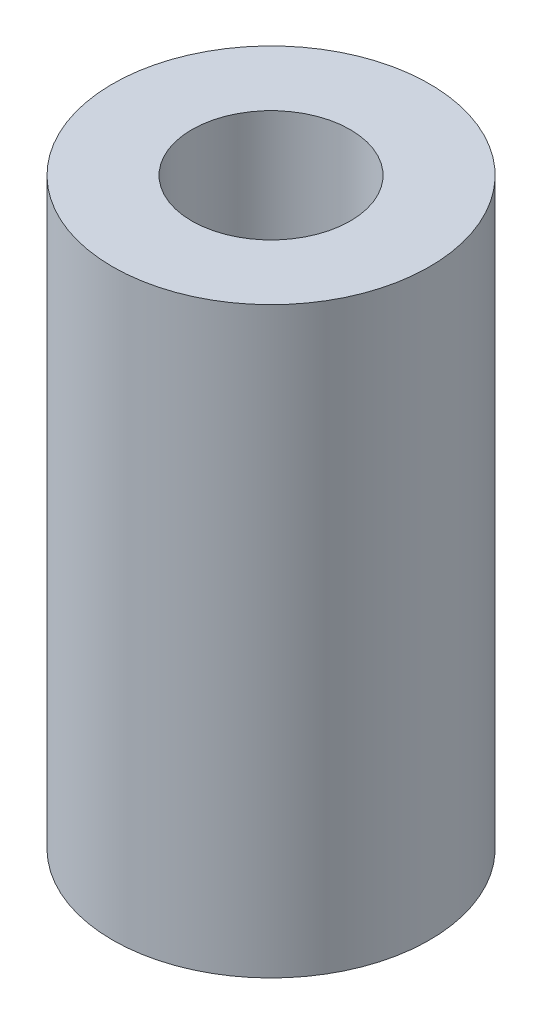
from build123d import *

# Parameters (mm, degrees)
SKETCH1_R           = 6.35
SKETCH1_R_2         = 3.175
BOSS_EXTRUDE1_DEPTH = 23.368


with BuildPart() as part:
    # Sketch1 → Boss-Extrude1 (new body)
    with BuildSketch(Plane(origin=(0, 0, 0), x_dir=(1, 0, 0), z_dir=(0, 1, 0))):
        Circle(SKETCH1_R)
        Circle(SKETCH1_R_2, mode=Mode.SUBTRACT)
    extrude(amount=BOSS_EXTRUDE1_DEPTH)


solid = part.part
